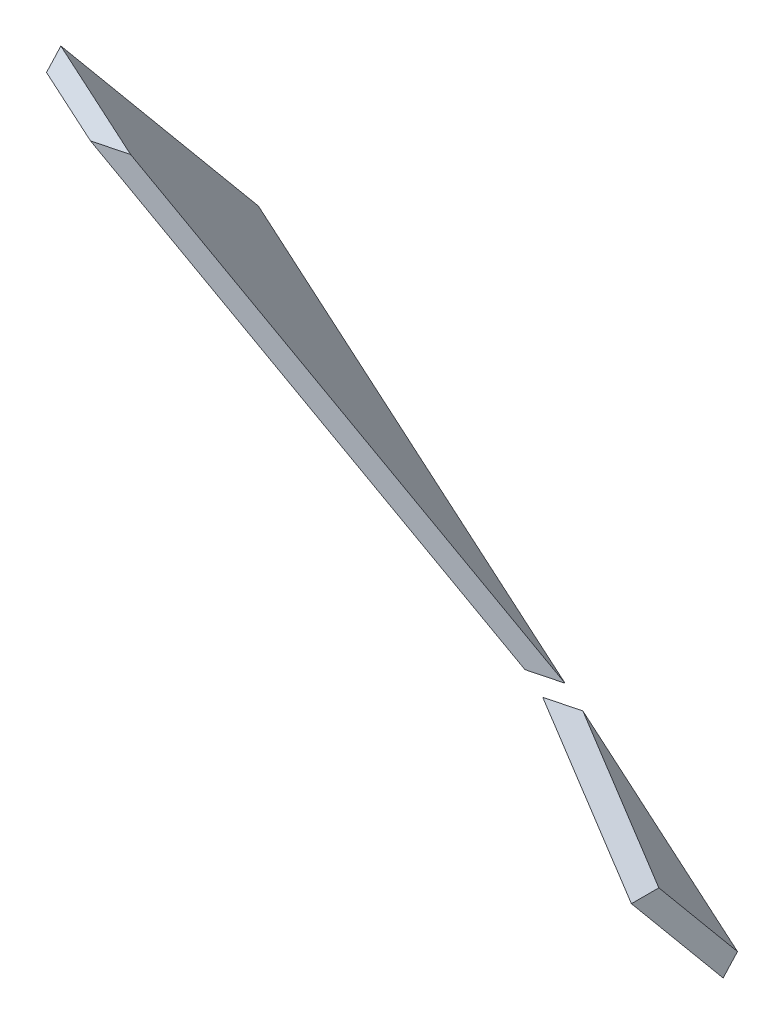
from build123d import *

# Parameters (mm, degrees)
BOSS_EXTRUDE3_DEPTH = 40
CUT_EXTRUDE1_DEPTH  = 58.863715208


with BuildPart() as part:
    # Sketch6 → Boss-Extrude3 (new body)
    with BuildSketch(Plane(origin=(-13.618312045, 66.066458327, 52.70195964), x_dir=(0.984335136, 0.075994886, 0.159088393), z_dir=(-0.159088393, 0.771784835, 0.615661475))):
        Polygon((89.043125981, 48.915913578), (88.358150123, 52.238933995), (-41.534636191, 89.973908512), (-40.849660333, 86.650888095), align=None)
    extrude(amount=BOSS_EXTRUDE3_DEPTH)

    # Sketch7 → Cut-Extrude1 (cut, through all)
    with BuildSketch(Plane(origin=(-20.295100688, 98.457534195, 0), x_dir=(0.968832963, 0.199706022, 0.146561234), z_dir=(-0.201886069, 0.979409013, 0))):
        Polygon((-12.235949059, -131.74056907), (234.668770197, -95.158885), (217.081422087, 23.54530695), (-29.823297169, -13.03637712), align=None)
    extrude(amount=CUT_EXTRUDE1_DEPTH, mode=Mode.SUBTRACT)


solid = part.part
